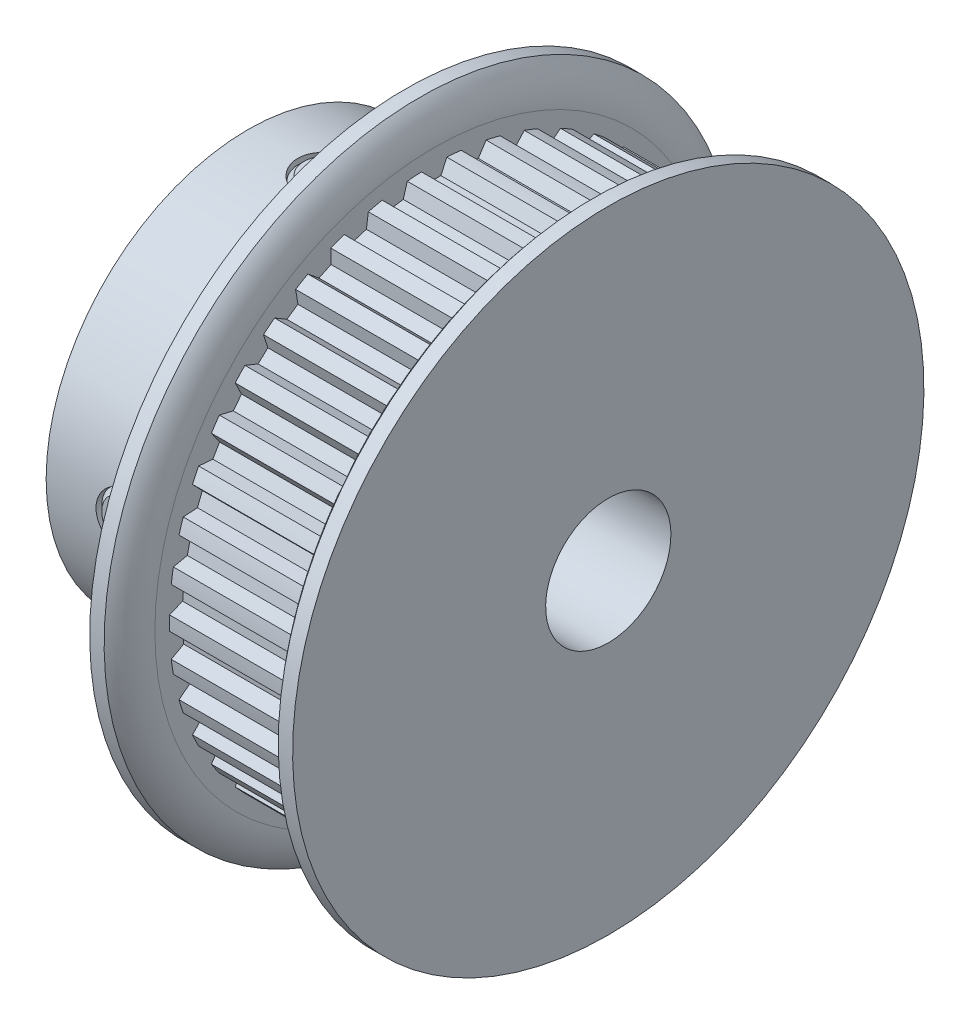
from build123d import *

# Parameters (mm, degrees)
SKETCH4_R          = 13.589
SKETCH4_R_2        = 13.43025
CUT_EXTRUDE2_DEPTH = 7.366
CUT_EXTRUDE1_DEPTH = 7.366
CIRPATTERN1_COUNT  = 42
SKETCH6_R          = 1.4605
CUT_EXTRUDE3_DEPTH = 25.403045869
CUT_EXTRUDE4_DEPTH = 1.016
CIRPATTERN2_COUNT  = 2
CIRPATTERN2_ANGLE  = 90
CIRPATTERN3_COUNT  = 2
CIRPATTERN3_ANGLE  = 90


with BuildPart() as part:
    # Sketch1 → Revolve1 (revolve)
    with BuildSketch(Plane.XY, mode=Mode.PRIVATE) as revolve1_sk:
        with BuildLine():
            Line((-9.1313, 3.175), (9.1313, 3.175))
            Line((9.1313, 3.175), (9.1313, 16.002))
            Line((9.1313, 16.002), (8.40105, 16.002))
            ThreePointArc((8.40105, 16.002), (7.860025322, 15.151003321), (7.6708, 14.1605))
            Line((7.6708, 14.1605), (7.6708, 13.589))
            Line((7.6708, 13.589), (0.3048, 13.589))
            Line((0.3048, 13.589), (0.3048, 14.1605))
            ThreePointArc((0.3048, 14.1605), (0.115574678, 15.151003321), (-0.42545, 16.002))
            Line((-0.42545, 16.002), (-1.1557, 16.002))
            Line((-1.1557, 16.002), (-1.1557, 10.2362))
            Line((-1.1557, 10.2362), (-9.1313, 10.2362))
            Line((-9.1313, 10.2362), (-9.1313, 3.175))
        make_face()
    revolve(revolve1_sk.sketch.rotate(Axis((-9.1313, 0, 0), (1, 0, 0)), 180), axis=Axis((-9.1313, 0, 0), (1, 0, 0)))

    # Sketch4 → Cut-Extrude2 (cut)
    with BuildSketch(Plane(origin=(0.3048, 0, 0), x_dir=(0, 0, -1), z_dir=(1, 0, 0))):
        Circle(SKETCH4_R)
        with Locations(Location((0, 0, 0), (0, 0, 90))):
            Circle(SKETCH4_R_2, mode=Mode.SUBTRACT)
    extrude(amount=CUT_EXTRUDE2_DEPTH, mode=Mode.SUBTRACT)

    # Sketch3 → Cut-Extrude1 (cut)
    with BuildSketch(Plane(origin=(0.3048, 0, 0), x_dir=(0, 0, -1), z_dir=(1, 0, 0))):
        with BuildLine():
            Line((-0.644061449, 13.414797796), (-0.338265727, 12.759016755))
            Line((-0.338265727, 12.759016755), (0.338265727, 12.759016755))
            Line((0.338265727, 12.759016755), (0.644061449, 13.414797796))
            ThreePointArc((0.644061449, 13.414797796), (0, 13.43025), (-0.644061449, 13.414797796))
        make_face()
    cut_extrude1 = extrude(amount=CUT_EXTRUDE1_DEPTH, mode=Mode.SUBTRACT)

    # CirPattern1: Cut-Extrude1 ×42 about axis
    cirpattern1_axis = Axis((0, 0, 0), (1, 0, 0))
    for i in range(1, CIRPATTERN1_COUNT):
        add(cut_extrude1.rotate(cirpattern1_axis, i * 360 / CIRPATTERN1_COUNT), mode=Mode.SUBTRACT)

    # Sketch6 → Cut-Extrude3 (cut, through all)
    with BuildSketch(Plane(origin=(0, 0, 0), x_dir=(1, 0, 0), z_dir=(0, 1, 0))):
        with Locations(Location((-5.1435, 0, 0), (0, 0, 90))):
            Circle(SKETCH6_R)
    cut_extrude3 = extrude(amount=CUT_EXTRUDE3_DEPTH, mode=Mode.SUBTRACT)

    # CirPattern2: Cut-Extrude3 ×2 about axis
    cirpattern2_axis = Axis((-9.1313, 0, 0), (1, 0, 0))
    for i in range(1, CIRPATTERN2_COUNT):
        add(cut_extrude3.rotate(cirpattern2_axis, i * CIRPATTERN2_ANGLE / (CIRPATTERN2_COUNT - 1)), mode=Mode.SUBTRACT)


with BuildPart() as body_2:
    # Sketch7 → Revolve2 (revolve)
    with BuildSketch(Plane.XY, mode=Mode.PRIVATE) as revolve2_sk:
        Polygon((-6.3119, 10.2362), (-5.1435, 10.2362), (-5.1435, 3.556), (-6.3119, 3.556), (-6.5659, 3.81), (-6.5659, 9.9822), align=None)
    revolve(revolve2_sk.sketch.rotate(Axis((-5.1435, 3.556, 0), (0, 1, 0)), 270), axis=Axis((-5.1435, 3.556, 0), (0, 1, 0)))

    # Sketch8 → Cut-Extrude4 (cut)
    with BuildSketch(Plane(origin=(0, 10.2362, 0), x_dir=(1, 0, 0), z_dir=(0, 1, 0))):
        Polygon((-5.1435, 0.821223023), (-5.8547, 0.410611511), (-5.8547, -0.410611511), (-5.1435, -0.821223023), (-4.4323, -0.410611511), (-4.4323, 0.410611511), align=None)
    extrude(amount=-CUT_EXTRUDE4_DEPTH, mode=Mode.SUBTRACT)


with BuildPart() as cirpattern3_1:
    # CirPattern3: pattern copy
    add(body_2.part.rotate(Axis((0, 0, 0), (1, 0, 0)), 1 * CIRPATTERN3_ANGLE / (CIRPATTERN3_COUNT - 1)))


solid = Compound([part.part, body_2.part, cirpattern3_1.part])
